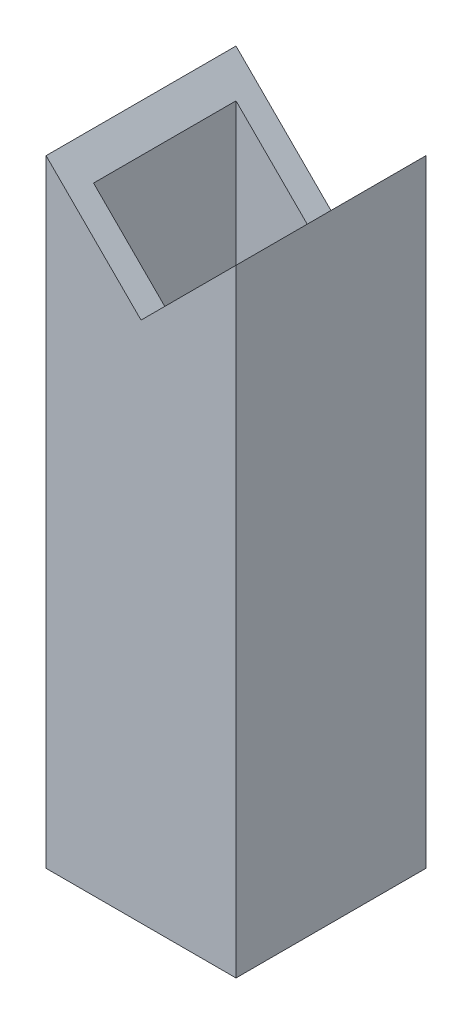
from build123d import *

# Parameters (mm, degrees)
SKETCH1_W               = 50.8
SKETCH1_H               = 50.8
SKETCH1_W_2             = 38.1
SKETCH1_H_2             = 38.1
BOSS_EXTRUDE1_DEPTH     = 82.55
CUT_EXTRUDE1_DEPTH      = 1
CUT_EXTRUDE1_DEPTH_BACK = 51.8


with BuildPart() as part:
    # Sketch1 → Boss-Extrude1 (new body, symmetric)
    with BuildSketch(Plane(origin=(0, 0, 0), x_dir=(1, 0, 0), z_dir=(0, 1, 0))):
        Rectangle(SKETCH1_W, SKETCH1_H)
        Rectangle(SKETCH1_W_2, SKETCH1_H_2, mode=Mode.SUBTRACT)
    extrude(amount=BOSS_EXTRUDE1_DEPTH, both=True)

    # Sketch3 → Cut-Extrude1 (cut, two sides)
    with BuildSketch(Plane.XY.offset(25.4)) as cut_extrude1_sk:
        Polygon((-276.760445395, 333.910445395), (-25.4, 82.55), (0, 57.15), (25.4, 82.55), (276.760445395, 333.910445395), (276.760445395, 1044.865147239), (-276.760445395, 1044.865147239), align=None)
    extrude(amount=CUT_EXTRUDE1_DEPTH, mode=Mode.SUBTRACT)
    extrude(cut_extrude1_sk.sketch, amount=-CUT_EXTRUDE1_DEPTH_BACK, mode=Mode.SUBTRACT)


solid = part.part
